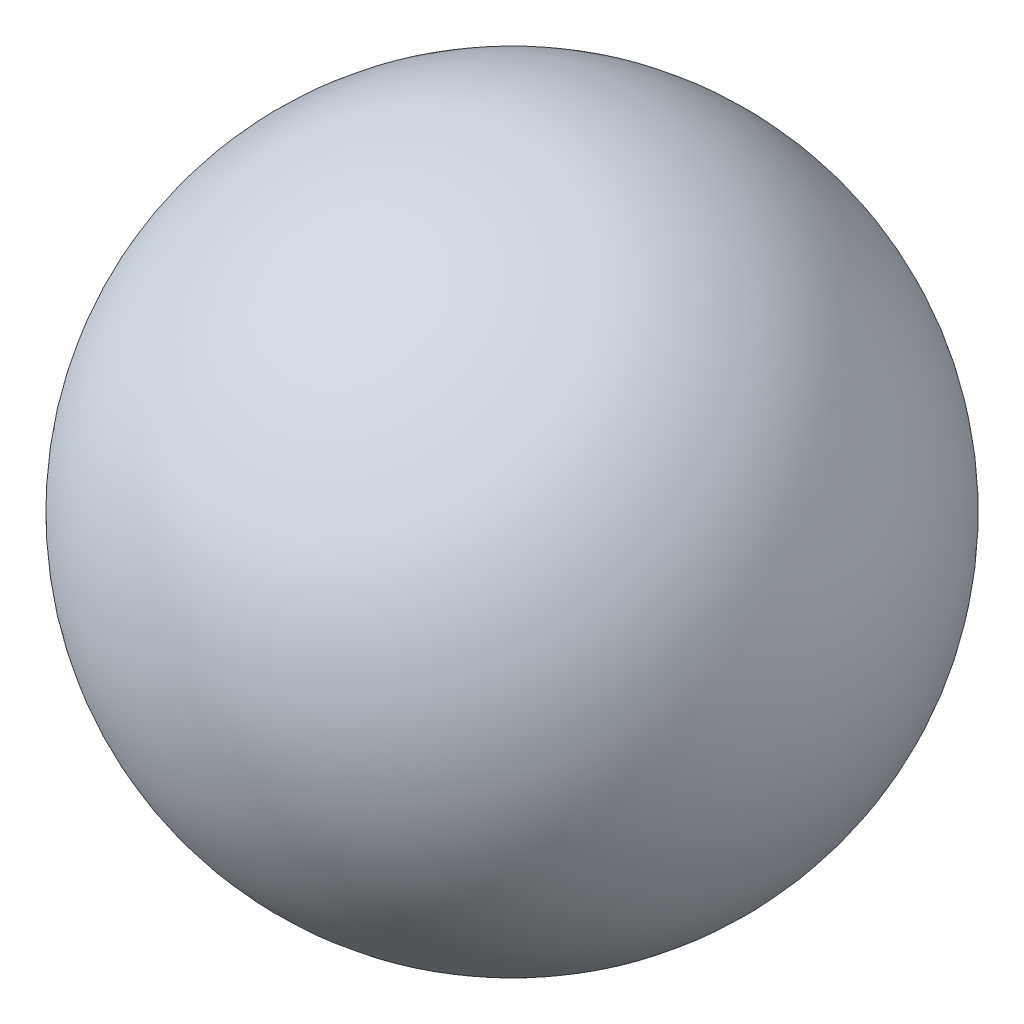
from build123d import *


with BuildPart() as part:
    # Croquis1 → Revolución2 (revolve)
    with BuildSketch(Plane.XY):
        with BuildLine():
            Line((0, 110), (0, -110))
            ThreePointArc((0, -110), (110, 0), (0, 110))
        make_face()
    revolve(axis=Axis((0, 110, 0), (0, -1, 0)))


solid = part.part
